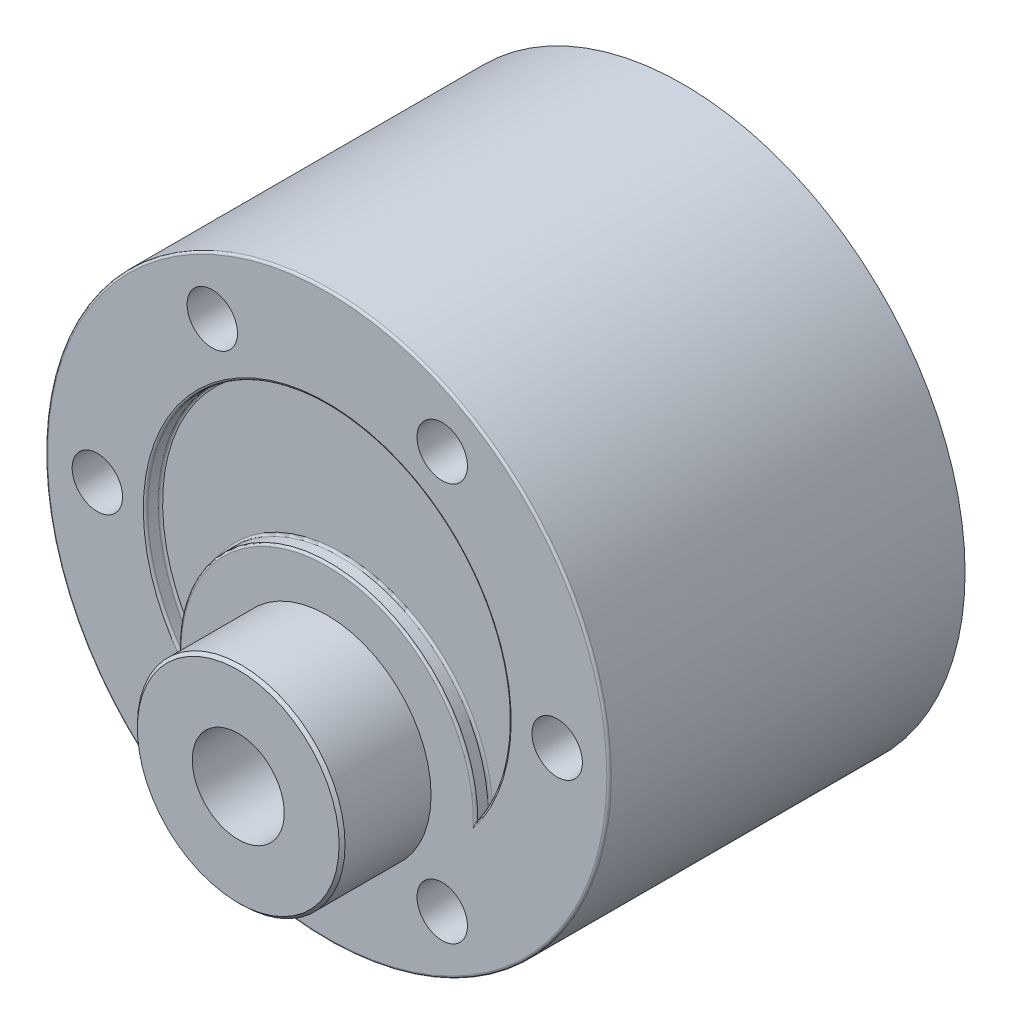
from build123d import *

# Parameters (mm, degrees)
SKETCH1_R                = 19
BOSS_EXTRUDE1_DEPTH      = 24
SKETCH3_R                = 12.25
CUT_EXTRUDE1_DEPTH       = 1
SKETCH4_R                = 10
BOSS_EXTRUDE4_DEPTH      = 1
SKETCH9_R                = 7
BOSS_EXTRUDE5_DEPTH      = 6
SKETCH10_R               = 3.1
CUT_EXTRUDE2_DEPTH       = 20
M3_CLEARANCE_HOLE1_D     = 3.4
M3_CLEARANCE_HOLE1_DEPTH = 3.5
M3_CLEARANCE_HOLE1_TIP   = 1.021463052
FILLET1_R                = 0.15
CHAMFER1_SIZE            = 0.2


with BuildPart() as part:
    # Sketch1 → Boss-Extrude1 (new body)
    with BuildSketch(Plane.XY):
        Circle(SKETCH1_R)
    extrude(amount=BOSS_EXTRUDE1_DEPTH)

    # Sketch3 → Cut-Extrude1 (cut)
    with BuildSketch(Plane.XY.offset(24)):
        Circle(SKETCH3_R)
    extrude(amount=-CUT_EXTRUDE1_DEPTH, mode=Mode.SUBTRACT)

    # Sketch4 → Boss-Extrude4 (add)
    with BuildSketch(Plane.XY.offset(23)):
        with Locations((0, -7)):
            Circle(SKETCH4_R)
    extrude(amount=BOSS_EXTRUDE4_DEPTH)

    # Sketch9 → Boss-Extrude5 (add)
    with BuildSketch(Plane.XY.offset(24)):
        with Locations((0, -7)):
            Circle(SKETCH9_R)
    extrude(amount=BOSS_EXTRUDE5_DEPTH)

    # Sketch10 → Cut-Extrude2 (cut)
    with BuildSketch(Plane.XY.offset(30)):
        with Locations((0, -7)):
            Circle(SKETCH10_R)
    extrude(amount=-CUT_EXTRUDE2_DEPTH, mode=Mode.SUBTRACT)

    # M3 Clearance Hole1
    with Locations(Plane.XY.offset(24)):
        with Locations((15.5, 0), (-15.5, 0), (-7.75, 13.423393759), (7.75, 13.423393759), (-7.75, -13.423393759), (7.75, -13.423393759)):
            Hole(M3_CLEARANCE_HOLE1_D / 2, depth=M3_CLEARANCE_HOLE1_DEPTH)
            with Locations((0, 0, -(M3_CLEARANCE_HOLE1_DEPTH + M3_CLEARANCE_HOLE1_TIP / 2))):  # 118° drill point
                Cone(0, M3_CLEARANCE_HOLE1_D / 2, M3_CLEARANCE_HOLE1_TIP, mode=Mode.SUBTRACT)

    # Fillet1
    fillet1_edges = [part.edges().sort_by_distance(p)[0] for p in [
        (0, 3, 23),
        (0, 12.25, 24),
        (0, 3, 24),
        (-19, 0, 24),
        (0, 12.25, 23),
    ]]
    fillet(fillet1_edges, radius=FILLET1_R)

    # Chamfer1
    chamfer1_edges = [part.edges().sort_by_distance(p)[0] for p in [
        (-7, -7, 30),
    ]]
    chamfer(chamfer1_edges, length=CHAMFER1_SIZE)


solid = part.part
